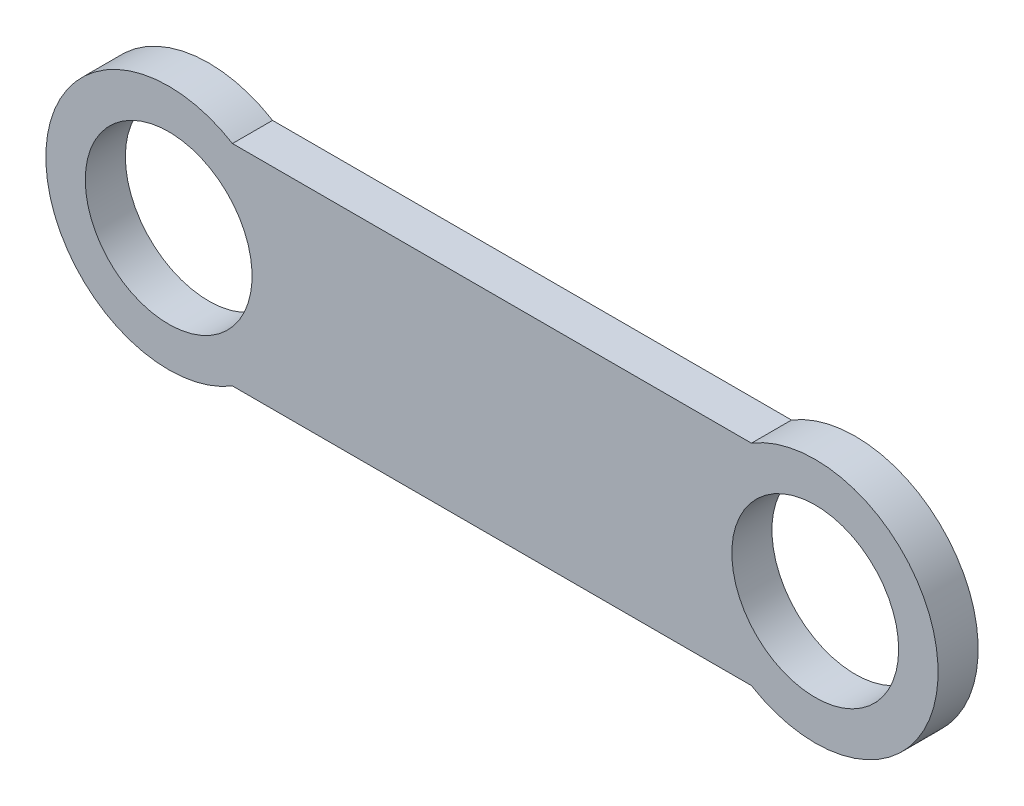
from build123d import *

# Parameters (mm, degrees)
SKETCH1_R           = 6.45
BOSS_EXTRUDE1_DEPTH = 3.1


with BuildPart() as part:
    # Sketch1 → Boss-Extrude1 (new body)
    with BuildSketch(Plane.XY):
        with BuildLine():
            Line((-20.066509578, 8.118538801), (20.066509578, 8.118538801))
            ThreePointArc((20.066509578, 8.118538801), (34.5, 0), (20.066509578, -8.118538801))
            Line((20.066509578, -8.118538801), (-20.066509578, -8.118538801))
            ThreePointArc((-20.066509578, -8.118538801), (-34.5, 0), (-20.066509578, 8.118538801))
        make_face()
        with Locations((25, 0)):
            Circle(SKETCH1_R, mode=Mode.SUBTRACT)
        with Locations((-25, 0)):
            Circle(SKETCH1_R, mode=Mode.SUBTRACT)
    extrude(amount=BOSS_EXTRUDE1_DEPTH)


solid = part.part
